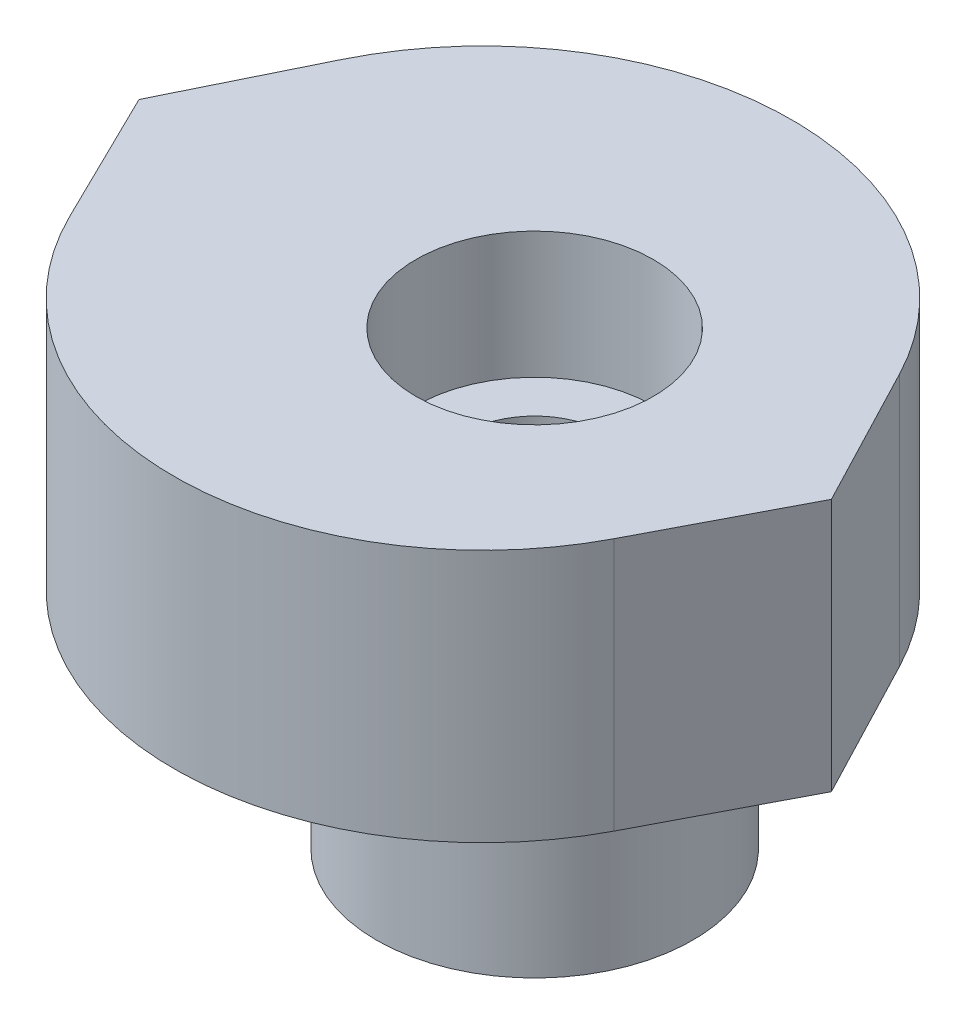
from build123d import *

# Parameters (mm, degrees)
SKETCH_1_R          = 1.8
EXTRUDE_1_DEPTH     = 6.4
SKETCH_7_R          = 3
CUT_EXTRUDE_1_DEPTH = 3.2
SKETCH_8_R          = 4
SKETCH_8_R_2        = 1.8
EXTRUDE_2_DEPTH     = 5
SKETCH_9_R          = 5.65
SKETCH_9_R_2        = 4
CUT_EXTRUDE_2_DEPTH = 2


with BuildPart() as part:
    # Эскиз1 → Бобышка-Вытянуть1 (new body)
    with BuildSketch(Plane(origin=(0, 0, 0), x_dir=(1, 0, 0), z_dir=(0, 1, 0))):
        with BuildLine():
            Line((-10, 0), (-8.31553819, 3.436118058))
            ThreePointArc((-8.31553819, 3.436118058), (-1.40535605, 7.805603403), (5.613555936, 3.613003503))
            Line((5.613555936, 3.613003503), (7.5, 0))
            Line((7.5, 0), (5.613555936, -3.613003503))
            ThreePointArc((5.613555936, -3.613003503), (-1.40535605, -7.805603403), (-8.31553819, -3.436118058))
            Line((-8.31553819, -3.436118058), (-10, 0))
        make_face()
        Circle(SKETCH_1_R, mode=Mode.SUBTRACT)
    extrude(amount=EXTRUDE_1_DEPTH)

    # Эскиз7 → Вырез-Вытянуть1 (cut)
    with BuildSketch(Plane(origin=(0, 6.4, 0), x_dir=(1, 0, 0), z_dir=(0, 1, 0))):
        Circle(SKETCH_7_R)
    extrude(amount=-CUT_EXTRUDE_1_DEPTH, mode=Mode.SUBTRACT)

    # Эскиз8 → Бобышка-Вытянуть2 (add)
    with BuildSketch(Plane.XZ):
        Circle(SKETCH_8_R)
        Circle(SKETCH_8_R_2, mode=Mode.SUBTRACT)
    extrude(amount=EXTRUDE_2_DEPTH)

    # Эскиз9 → Вырез-Вытянуть2 (cut)
    with BuildSketch(Plane.XZ):
        Circle(SKETCH_9_R)
        Circle(SKETCH_9_R_2, mode=Mode.SUBTRACT)
    extrude(amount=-CUT_EXTRUDE_2_DEPTH, mode=Mode.SUBTRACT)


solid = part.part
